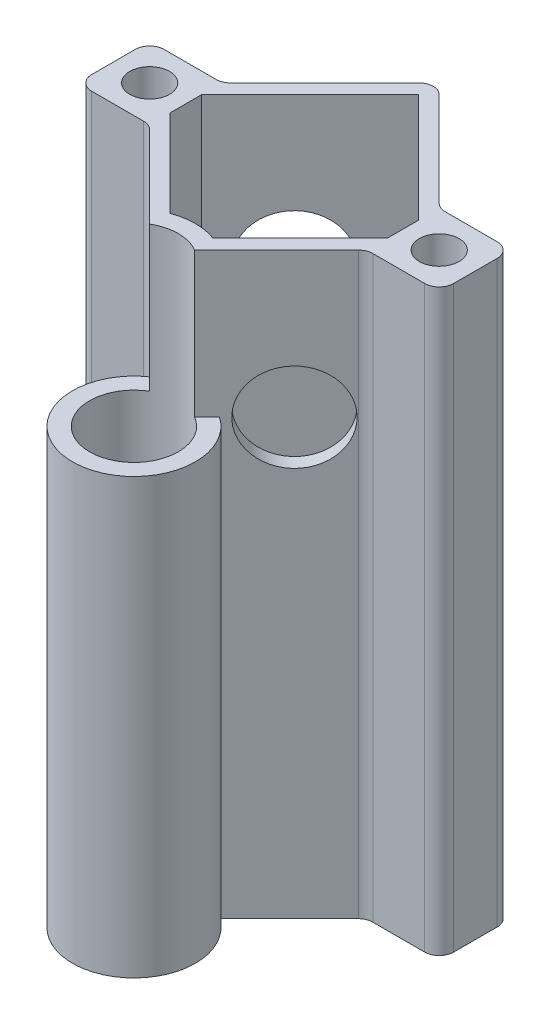
from build123d import *

# Parameters (mm, degrees)
SKETCH2_R               = 3.4925
BOSS_EXTRUDE1_DEPTH     = 101.6
FILLET1_R               = 2.54
SKETCH12_R              = 7.77875
CUT_EXTRUDE2_DEPTH      = 22.706691527
CUT_EXTRUDE2_DEPTH_BACK = 58.627716011
SKETCH13_R              = 7.77875
CUT_EXTRUDE3_DEPTH      = 22.706691527
CUT_EXTRUDE3_DEPTH_BACK = 58.627716011
SKETCH14_R              = 10.795
SKETCH14_R_2            = 7.77875
BOSS_EXTRUDE2_DEPTH     = 76.2
SKETCH14_2_R            = 7.77875
CUT_EXTRUDE4_DEPTH      = 102.6
BOSS_EXTRUDE3_DEPTH     = 25.4


with BuildPart() as part:
    # Sketch2 → Boss-Extrude1 (new body)
    with BuildSketch(Plane(origin=(0, 0, 0), x_dir=(1, 0, 0), z_dir=(0, 1, 0))):
        Polygon((19.05, -6.35), (31.75, -6.35), (31.75, 6.35), (19.05, 6.35), (0, 25.4), (-19.05, 6.35), (-31.75, 6.35), (-31.75, -6.35), (-19.05, -6.35), (0, -25.4), align=None)
        Polygon((-19.05, 2.757897552), (0, 21.807897552), (19.05, 2.757897552), (19.05, -2.757897552), (0, -21.807897552), (-19.05, -2.757897552), align=None, mode=Mode.SUBTRACT)
        with Locations((25.4, 0)):
            Circle(SKETCH2_R, mode=Mode.SUBTRACT)
        with Locations((-25.4, 0)):
            Circle(SKETCH2_R, mode=Mode.SUBTRACT)
    extrude(amount=BOSS_EXTRUDE1_DEPTH)

    # Fillet1
    fillet1_edges = [part.edges().sort_by_distance(p)[0] for p in [
        (0, 50.8, 25.4),
        (-19.05, 50.8, 6.35),
        (-31.75, 50.8, 6.35),
        (-31.75, 50.8, -6.35),
        (-19.05, 50.8, -6.35),
        (0, 50.8, -25.4),
        (19.05, 50.8, -6.35),
        (31.75, 50.8, -6.35),
        (31.75, 50.8, 6.35),
        (19.05, 50.8, 6.35),
    ]]
    fillet(fillet1_edges, radius=FILLET1_R)

    # Sketch12 → Cut-Extrude2 (cut, two sides)
    with BuildSketch(Plane(origin=(-12.7, 0, -12.7), x_dir=(-0.707106781, 0, 0.707106781), z_dir=(-0.707106781, 0, -0.707106781))) as cut_extrude2_sk:
        with Locations((0, 76.2)):
            Circle(SKETCH12_R)
    extrude(amount=CUT_EXTRUDE2_DEPTH, mode=Mode.SUBTRACT)
    extrude(cut_extrude2_sk.sketch, amount=-CUT_EXTRUDE2_DEPTH_BACK, mode=Mode.SUBTRACT)

    # Sketch13 → Cut-Extrude3 (cut, two sides)
    with BuildSketch(Plane(origin=(12.7, 0, -12.7), x_dir=(-0.707106781, 0, -0.707106781), z_dir=(0.707106781, 0, -0.707106781))) as cut_extrude3_sk:
        with Locations((0, 50.8)):
            Circle(SKETCH13_R)
    extrude(amount=CUT_EXTRUDE3_DEPTH, mode=Mode.SUBTRACT)
    extrude(cut_extrude3_sk.sketch, amount=-CUT_EXTRUDE3_DEPTH_BACK, mode=Mode.SUBTRACT)

    # Sketch14 → Boss-Extrude2 (add)
    with BuildSketch(Plane.XZ):
        with Locations((0, 28.157897552)):
            Circle(SKETCH14_R)
        with Locations((0, 28.157897552)):
            Circle(SKETCH14_R_2, mode=Mode.SUBTRACT)
    extrude(amount=-BOSS_EXTRUDE2_DEPTH)

    # Sketch14_2 → Cut-Extrude4 (cut, through all)
    with BuildSketch(Plane.XZ):
        with Locations((0, 28.157897552)):
            Circle(SKETCH14_2_R)
    extrude(amount=-CUT_EXTRUDE4_DEPTH, mode=Mode.SUBTRACT)

    # Sketch15 → Boss-Extrude3 (add)
    with BuildSketch(Plane(origin=(0, 76.2, 0), x_dir=(1, 0, 0), z_dir=(0, 1, 0))):
        with BuildLine():
            Line((1.316531006, -20.491366545), (3.766569527, -18.041328024))
            ThreePointArc((3.766569527, -18.041328024), (0, -17.362897552), (-3.766569527, -18.041328024))
            Line((-3.766569527, -18.041328024), (-1.316531006, -20.491366545))
            ThreePointArc((-1.316531006, -20.491366545), (0, -20.379147552), (1.316531006, -20.491366545))
        make_face()
    extrude(amount=BOSS_EXTRUDE3_DEPTH)


solid = part.part
